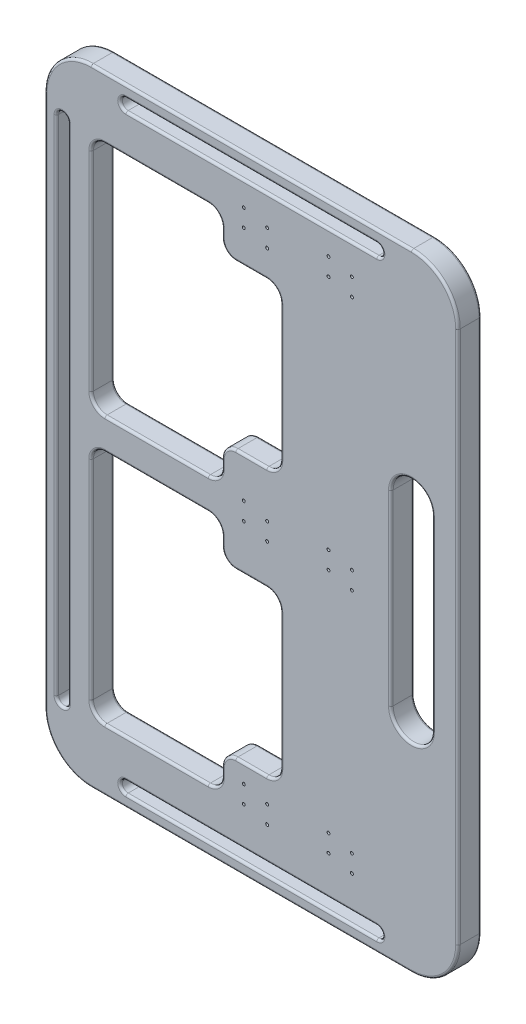
from build123d import *

# Parameters (mm, degrees)
BOSS_EXTRUDE1_DEPTH = 25.4
FILLET1_R           = 2.54
HOLE2_D             = 3.175
HOLE2_DEPTH         = 31.75
HOLE2_CBORE_D       = 5.7404
HOLE2_CBORE_DEPTH   = 3.5052


with BuildPart() as part:
    # Sketch1 → Boss-Extrude1 (new body)
    with BuildSketch(Plane.XY):
        with BuildLine():
            Line((178.841291268, 5.830748671), (-169.316291268, 5.830748671))
            ThreePointArc((-169.316291268, 5.830748671), (-205.029031455, -8.961952664), (-219.821732791, -44.674692852))
            Line((-219.821732791, -44.674692852), (-219.821732791, -624.167422709))
            ThreePointArc((-219.821732791, -624.167422709), (-205.029031455, -659.880162896), (-169.316291268, -674.672864232))
            Line((-169.316291268, -674.672864232), (178.841291268, -674.672864232))
            ThreePointArc((178.841291268, -674.672864232), (214.554031455, -659.880162896), (229.346732791, -624.167422709))
            Line((229.346732791, -624.167422709), (229.346732791, -44.674692852))
            ThreePointArc((229.346732791, -44.674692852), (214.554031455, -8.961952664), (178.841291268, 5.830748671))
        make_face()
        with BuildLine():
            Line((201.277190257, -232.82105778), (201.277190257, -436.02105778))
            ThreePointArc((201.277190257, -436.02105778), (178.841291268, -458.45695677), (156.405392278, -436.02105778))
            Line((156.405392278, -436.02105778), (156.405392278, -232.82105778))
            ThreePointArc((156.405392278, -232.82105778), (178.841291268, -210.385158791), (201.277190257, -232.82105778))
        make_face(mode=Mode.SUBTRACT)
        with BuildLine():
            Line((-42.021732791, -61.084457743), (-154.370849745, -61.084457743))
            ThreePointArc((-154.370849745, -61.084457743), (-164.938872794, -65.461876217), (-169.316291268, -76.029899266))
            Line((-169.316291268, -76.029899266), (-169.316291268, -302.554558477))
            ThreePointArc((-169.316291268, -302.554558477), (-164.938872794, -313.122581526), (-154.370849745, -317.5))
            Line((-154.370849745, -317.5), (-42.021732791, -317.5))
            ThreePointArc((-42.021732791, -317.5), (-31.453709742, -313.122581526), (-27.076291268, -302.554558477))
            Line((-27.076291268, -302.554558477), (-27.076291268, -292.963135522))
            ThreePointArc((-27.076291268, -292.963135522), (-22.698872794, -282.395112473), (-12.130849745, -278.017693999))
            Line((-12.130849745, -278.017693999), (21.478267209, -278.017693999))
            ThreePointArc((21.478267209, -278.017693999), (32.046290258, -273.640275525), (36.423708732, -263.072252476))
            Line((36.423708732, -263.072252476), (36.423708732, -115.512205267))
            ThreePointArc((36.423708732, -115.512205267), (32.046290258, -104.944182218), (21.478267209, -100.566763744))
            Line((21.478267209, -100.566763744), (-12.130849745, -100.566763744))
            ThreePointArc((-12.130849745, -100.566763744), (-22.698872794, -96.18934527), (-27.076291268, -85.621322221))
            Line((-27.076291268, -85.621322221), (-27.076291268, -76.029899266))
            ThreePointArc((-27.076291268, -76.029899266), (-31.453709742, -65.461876217), (-42.021732791, -61.084457743))
        make_face(mode=Mode.SUBTRACT)
        with BuildLine():
            Line((-131.519577428, -6.869251329), (141.044577428, -6.869251329))
            ThreePointArc((141.044577428, -6.869251329), (147.394577428, -13.219251329), (141.044577428, -19.569251329))
            Line((141.044577428, -19.569251329), (-131.519577428, -19.569251329))
            ThreePointArc((-131.519577428, -19.569251329), (-137.869577428, -13.219251329), (-131.519577428, -6.869251329))
        make_face(mode=Mode.SUBTRACT)
        with BuildLine():
            Line((-27.076291268, -375.878980039), (-27.076291268, -366.287557083))
            ThreePointArc((-27.076291268, -366.287557083), (-31.453709742, -355.719534035), (-42.021732791, -351.34211556))
            Line((-42.021732791, -351.34211556), (-154.370849745, -351.34211556))
            ThreePointArc((-154.370849745, -351.34211556), (-164.938872794, -355.719534035), (-169.316291268, -366.287557083))
            Line((-169.316291268, -366.287557083), (-169.316291268, -592.812216295))
            ThreePointArc((-169.316291268, -592.812216295), (-164.938872794, -603.380239343), (-154.370849745, -607.757657817))
            Line((-154.370849745, -607.757657817), (-42.021732791, -607.757657817))
            ThreePointArc((-42.021732791, -607.757657817), (-31.453709742, -603.380239343), (-27.076291268, -592.812216295))
            Line((-27.076291268, -592.812216295), (-27.076291268, -583.220793339))
            ThreePointArc((-27.076291268, -583.220793339), (-22.698872794, -572.652770291), (-12.130849745, -568.275351817))
            Line((-12.130849745, -568.275351817), (21.478267209, -568.275351817))
            ThreePointArc((21.478267209, -568.275351817), (32.046290258, -563.897933342), (36.423708732, -553.329910294))
            Line((36.423708732, -553.329910294), (36.423708732, -405.769863084))
            ThreePointArc((36.423708732, -405.769863084), (32.046290258, -395.201840036), (21.478267209, -390.824421561))
            Line((21.478267209, -390.824421561), (-12.130849745, -390.824421561))
            ThreePointArc((-12.130849745, -390.824421561), (-22.698872794, -386.447003087), (-27.076291268, -375.878980039))
        make_face(mode=Mode.SUBTRACT)
        with BuildLine():
            Line((-207.121732791, -607.757657817), (-207.121732791, -61.084457743))
            ThreePointArc((-207.121732791, -61.084457743), (-200.771732791, -54.734457743), (-194.421732791, -61.084457743))
            Line((-194.421732791, -61.084457743), (-194.421732791, -607.757657817))
            ThreePointArc((-194.421732791, -607.757657817), (-200.771732791, -614.107657817), (-207.121732791, -607.757657817))
        make_face(mode=Mode.SUBTRACT)
        with BuildLine():
            Line((-131.519577428, -661.972864232), (141.044577428, -661.972864232))
            ThreePointArc((141.044577428, -661.972864232), (147.394577428, -655.622864232), (141.044577428, -649.272864232))
            Line((141.044577428, -649.272864232), (-131.519577428, -649.272864232))
            ThreePointArc((-131.519577428, -649.272864232), (-137.869577428, -655.622864232), (-131.519577428, -661.972864232))
        make_face(mode=Mode.SUBTRACT)
    extrude(amount=BOSS_EXTRUDE1_DEPTH)

    # Fillet1
    fillet1_edges = [part.edges().sort_by_distance(p)[0] for p in [
        (229.346732791, -334.42105778, 0),
        (-22.698872794, -386.447003087, 0),
        (-27.076291268, -371.083268561, 0),
        (214.554031455, -659.880162896, 0),
        (-31.453709742, -355.719534035, 0),
        (-98.196291268, -351.34211556, 0),
        (-164.938872794, -355.719534035, 0),
        (-169.316291268, -479.549886689, 0),
        (-164.938872794, -603.380239343, 0),
        (-98.196291268, -607.757657817, 0),
        (-31.453709742, -603.380239343, 0),
        (-27.076291268, -588.016504817, 0),
        (-22.698872794, -572.652770291, 0),
        (4.673708732, -568.275351817, 0),
        (4.7625, -674.672864232, 0),
        (32.046290258, -563.897933342, 0),
        (36.423708732, -479.549886689, 0),
        (32.046290258, -395.201840036, 0),
        (4.673708732, -390.824421561, 0),
        (-22.698872794, -386.447003087, 25.4),
        (-27.076291268, -371.083268561, 25.4),
        (-31.453709742, -355.719534035, 25.4),
        (-98.196291268, -351.34211556, 25.4),
        (-164.938872794, -355.719534035, 25.4),
        (-169.316291268, -479.549886689, 25.4),
        (-164.938872794, -603.380239343, 25.4),
        (-205.029031455, -659.880162896, 0),
        (-98.196291268, -607.757657817, 25.4),
        (-31.453709742, -603.380239343, 25.4),
        (-27.076291268, -588.016504817, 25.4),
        (-22.698872794, -572.652770291, 25.4),
        (4.673708732, -568.275351817, 25.4),
        (32.046290258, -563.897933342, 25.4),
        (36.423708732, -479.549886689, 25.4),
        (32.046290258, -395.201840036, 25.4),
        (4.673708732, -390.824421561, 25.4),
        (214.554031455, -659.880162896, 25.4),
        (-200.771732791, -614.107657817, 0),
        (-194.421732791, -334.42105778, 0),
        (-200.771732791, -54.734457743, 0),
        (-207.121732791, -334.42105778, 0),
        (-200.771732791, -614.107657817, 25.4),
        (-194.421732791, -334.42105778, 25.4),
        (-200.771732791, -54.734457743, 25.4),
        (-207.121732791, -334.42105778, 25.4),
        (-137.869577428, -655.622864232, 0),
        (4.7625, -661.972864232, 0),
        (147.394577428, -655.622864232, 0),
        (4.7625, -649.272864232, 0),
        (-137.869577428, -655.622864232, 25.4),
        (4.7625, -661.972864232, 25.4),
        (147.394577428, -655.622864232, 25.4),
        (4.7625, -649.272864232, 25.4),
        (229.346732791, -334.42105778, 25.4),
        (214.554031455, -8.961952664, 25.4),
        (178.841291268, -210.385158791, 0),
        (156.405392278, -334.42105778, 0),
        (4.7625, 5.830748671, 25.4),
        (178.841291268, -458.45695677, 0),
        (201.277190257, -334.42105778, 0),
        (178.841291268, -210.385158791, 25.4),
        (156.405392278, -334.42105778, 25.4),
        (178.841291268, -458.45695677, 25.4),
        (201.277190257, -334.42105778, 25.4),
        (-205.029031455, -8.961952664, 25.4),
        (-219.821732791, -334.42105778, 25.4),
        (-137.869577428, -13.219251329, 0),
        (4.7625, -19.569251329, 0),
        (147.394577428, -13.219251329, 0),
        (4.7625, -6.869251329, 0),
        (-137.869577428, -13.219251329, 25.4),
        (4.7625, -19.569251329, 25.4),
        (147.394577428, -13.219251329, 25.4),
        (4.7625, -6.869251329, 25.4),
        (-205.029031455, -659.880162896, 25.4),
        (32.046290258, -104.944182218, 0),
        (4.673708732, -100.566763744, 0),
        (-22.698872794, -96.18934527, 0),
        (-27.076291268, -80.825610743, 0),
        (-31.453709742, -65.461876217, 0),
        (-98.196291268, -61.084457743, 0),
        (-164.938872794, -65.461876217, 0),
        (-169.316291268, -189.292228872, 0),
        (-164.938872794, -313.122581526, 0),
        (-98.196291268, -317.5, 0),
        (-31.453709742, -313.122581526, 0),
        (-27.076291268, -297.758847, 0),
        (-22.698872794, -282.395112473, 0),
        (4.673708732, -278.017693999, 0),
        (32.046290258, -273.640275525, 0),
        (36.423708732, -189.292228872, 0),
        (32.046290258, -104.944182218, 25.4),
        (4.673708732, -100.566763744, 25.4),
        (-22.698872794, -96.18934527, 25.4),
        (-27.076291268, -80.825610743, 25.4),
        (-31.453709742, -65.461876217, 25.4),
        (-98.196291268, -61.084457743, 25.4),
        (-164.938872794, -65.461876217, 25.4),
        (-169.316291268, -189.292228872, 25.4),
        (-164.938872794, -313.122581526, 25.4),
        (-98.196291268, -317.5, 25.4),
        (-31.453709742, -313.122581526, 25.4),
        (-27.076291268, -297.758847, 25.4),
        (-22.698872794, -282.395112473, 25.4),
        (4.673708732, -278.017693999, 25.4),
        (32.046290258, -273.640275525, 25.4),
        (36.423708732, -189.292228872, 25.4),
        (-219.821732791, -334.42105778, 0),
        (4.7625, -674.672864232, 25.4),
        (-205.029031455, -8.961952664, 0),
        (4.7625, 5.830748671, 0),
        (214.554031455, -8.961952664, 0),
    ]]
    fillet(fillet1_edges, radius=FILLET1_R)

    # Hole2
    with Locations(Plane(origin=(0, 0, 0), x_dir=(-1, 0, 0), z_dir=(0, 0, -1))):
        with Locations((-114.053377526, -52.003972738), (-114.053377526, -71.053972738), (-88.653377526, -45.653972738), (-88.653377526, -64.703972738), (3.421622474, -45.653972738), (3.421622474, -64.703972738), (-21.978377526, -52.003972738), (-21.978377526, -71.053972738), (-21.978377526, -328.07105778), (-21.978377526, -347.12105778), (3.421622474, -340.77105778), (3.421622474, -321.72105778), (-114.053377526, -594.570172231), (-114.053377526, -613.620172231), (-88.653377526, -607.270172231), (-88.653377526, -588.220172231), (3.421622474, -588.220172231), (3.421622474, -607.270172231), (-21.978377526, -594.570172231), (-21.978377526, -613.620172231), (-88.653377526, -340.77105778), (-88.653377526, -321.72105778), (-114.053377526, -347.12105778), (-114.053377526, -328.07105778)):
            CounterBoreHole(HOLE2_D / 2, HOLE2_CBORE_D / 2, HOLE2_CBORE_DEPTH, depth=HOLE2_DEPTH)


solid = part.part
